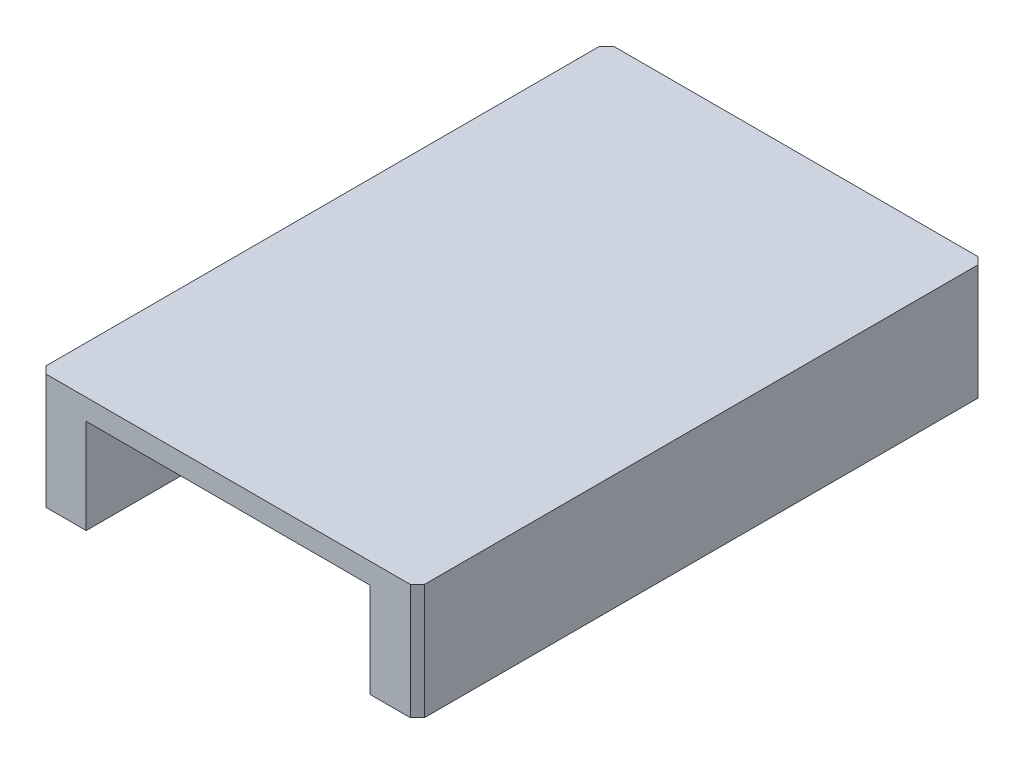
from build123d import *

# Parameters (mm, degrees)
SCHIZZO1_W                        = 60
SCHIZZO1_H                        = 7.2
SCHIZZO1_W_2                      = 19.125
SCHIZZO1_H_2                      = 5
ESTRUSIONE_ESTRUSIONE1_DEPTH      = 40
SCHIZZO2_W                        = 11.375
SCHIZZO2_H                        = 5
SCHIZZO2_W_2                      = 2.075
SCHIZZO2_H_2                      = 1.1
SCHIZZO2_W_3                      = 2.05
TAGLIO_ESTRUSIONE1_DEPTH          = 61
SMUSSO1_SIZE                      = 0.75
SCHIZZO3_W                        = 7.25
SCHIZZO3_H                        = 5
TAGLIO_ESTRUSIONE2_DEPTH          = 64
SCHIZZO4_W                        = 38.5
SCHIZZO4_H                        = 1.1
ESTRUSIONE_ESTRUSIONE3_DEPTH      = 60
SCHIZZO7_W                        = 30
SCHIZZO7_H                        = 1.1
ESTRUSIONE_ESTRUSIONE4_DEPTH      = 50
ESTRUSIONE_ESTRUSIONE5_DEPTH      = 5
SCHIZZO9_W                        = 19.125
SCHIZZO9_H                        = 1.1
ESTRUSIONE_ESTRUSIONE6_DEPTH      = 5
ESTRUSIONE_ESTRUSIONE6_DEPTH_BACK = 35
SCHIZZO10_W                       = 19.125
SCHIZZO10_H                       = 3.9
TAGLIO_ESTRUSIONE3_DEPTH          = 41
SCHIZZO11_W                       = 19.125
SCHIZZO11_H                       = 7.8
ESTRUSIONE_ESTRUSIONE7_DEPTH      = 40
SCHIZZO12_W                       = 30
SCHIZZO12_H                       = 10
TAGLIO_ESTRUSIONE4_DEPTH          = 64


with BuildPart() as part:
    # Schizzo1 → Estrusione-Estrusione1 (new body)
    with BuildSketch(Plane(origin=(0, 0, 0), x_dir=(0, 0, -1), z_dir=(1, 0, 0))):
        with Locations((30, 3.6)):
            Rectangle(SCHIZZO1_W, SCHIZZO1_H)
        with Locations((43.1875, 3.6)):
            Rectangle(SCHIZZO1_W_2, SCHIZZO1_H_2, mode=Mode.SUBTRACT)
        with Locations((16.8125, 3.6)):
            Rectangle(SCHIZZO1_W_2, SCHIZZO1_H_2, mode=Mode.SUBTRACT)
    extrude(amount=ESTRUSIONE_ESTRUSIONE1_DEPTH)

    # Schizzo2 → Taglio-Estrusione1 (cut, through all)
    with BuildSketch(Plane.XY):
        with Locations((10.6875, 2.5)):
            Rectangle(SCHIZZO2_W, SCHIZZO2_H)
        with Locations((29.3125, 2.5)):
            Rectangle(SCHIZZO2_W, SCHIZZO2_H)
        with Locations((15.3375, 6.65)):
            Rectangle(SCHIZZO2_W_2, SCHIZZO2_H_2)
        with Locations((8.275, 6.65)):
            Rectangle(SCHIZZO2_W_3, SCHIZZO2_H_2)
        with Locations((24.6625, 6.65)):
            Rectangle(SCHIZZO2_W_2, SCHIZZO2_H_2)
        with Locations((31.725, 6.65)):
            Rectangle(SCHIZZO2_W_3, SCHIZZO2_H_2)
    extrude(amount=-TAGLIO_ESTRUSIONE1_DEPTH, mode=Mode.SUBTRACT)

    # Smusso1
    smusso1_edges = [part.edges().sort_by_distance(p)[0] for p in [
        (40, 3.6, 0),
        (0, 3.6, 0),
        (0, 3.6, -60),
        (40, 3.6, -60),
    ]]
    chamfer(smusso1_edges, length=SMUSSO1_SIZE)

    # Schizzo3 → Taglio-Estrusione2 (cut)
    with BuildSketch(Plane.XY):
        with Locations((20, 2.5)):
            Rectangle(SCHIZZO3_W, SCHIZZO3_H)
    extrude(amount=-TAGLIO_ESTRUSIONE2_DEPTH, mode=Mode.SUBTRACT)

    # Schizzo4 → Estrusione-Estrusione3 (add)
    with BuildSketch(Plane.XY):
        with Locations((20, 6.65)):
            Rectangle(SCHIZZO4_W, SCHIZZO4_H)
    extrude(amount=-ESTRUSIONE_ESTRUSIONE3_DEPTH)

    # Schizzo7 → Estrusione-Estrusione4 (add)
    with BuildSketch(Plane.XY.offset(-52.75)):
        with Locations((20, 5.55)):
            Rectangle(SCHIZZO7_W, SCHIZZO7_H)
    extrude(amount=ESTRUSIONE_ESTRUSIONE4_DEPTH)

    # Schizzo8 → Estrusione-Estrusione5 (add)
    with BuildSketch(Plane.XZ):
        Polygon((5, 0), (0.75, 0), (0, -0.75), (0, -59.25), (0.75, -60), (5, -60), align=None)
        Polygon((35, 0), (35, -60), (39.25, -60), (40, -59.25), (40, -0.75), (39.25, 0), align=None)
    extrude(amount=ESTRUSIONE_ESTRUSIONE5_DEPTH)

    # Schizzo9 → Estrusione-Estrusione6 (add, two sides)
    with BuildSketch(Plane(origin=(35, 0, 0), x_dir=(0, 0, -1), z_dir=(1, 0, 0))) as estrusione_estrusione6_sk:
        with Locations((16.8125, 5.55)):
            Rectangle(SCHIZZO9_W, SCHIZZO9_H)
        with Locations((43.1875, 5.55)):
            Rectangle(SCHIZZO9_W, SCHIZZO9_H)
    extrude(amount=ESTRUSIONE_ESTRUSIONE6_DEPTH)
    extrude(estrusione_estrusione6_sk.sketch, amount=-ESTRUSIONE_ESTRUSIONE6_DEPTH_BACK)

    # Schizzo10 → Taglio-Estrusione3 (cut, through all)
    with BuildSketch(Plane.ZY):
        with Locations((-43.1875, -0.85)):
            Rectangle(SCHIZZO10_W, SCHIZZO10_H)
        with Locations((-16.8125, -0.85)):
            Rectangle(SCHIZZO10_W, SCHIZZO10_H)
    extrude(amount=-TAGLIO_ESTRUSIONE3_DEPTH, mode=Mode.SUBTRACT)

    # Schizzo11 → Estrusione-Estrusione7 (add)
    with BuildSketch(Plane.ZY):
        with Locations((-43.1875, 1.1)):
            Rectangle(SCHIZZO11_W, SCHIZZO11_H)
        with Locations((-16.8125, 1.1)):
            Rectangle(SCHIZZO11_W, SCHIZZO11_H)
    extrude(amount=-ESTRUSIONE_ESTRUSIONE7_DEPTH)

    # Schizzo12 → Taglio-Estrusione4 (cut)
    with BuildSketch(Plane(origin=(0, 0, -60), x_dir=(-1, 0, 0), z_dir=(0, 0, -1))):
        with Locations((-20, 0)):
            Rectangle(SCHIZZO12_W, SCHIZZO12_H)
    extrude(amount=-TAGLIO_ESTRUSIONE4_DEPTH, mode=Mode.SUBTRACT)


solid = part.part
